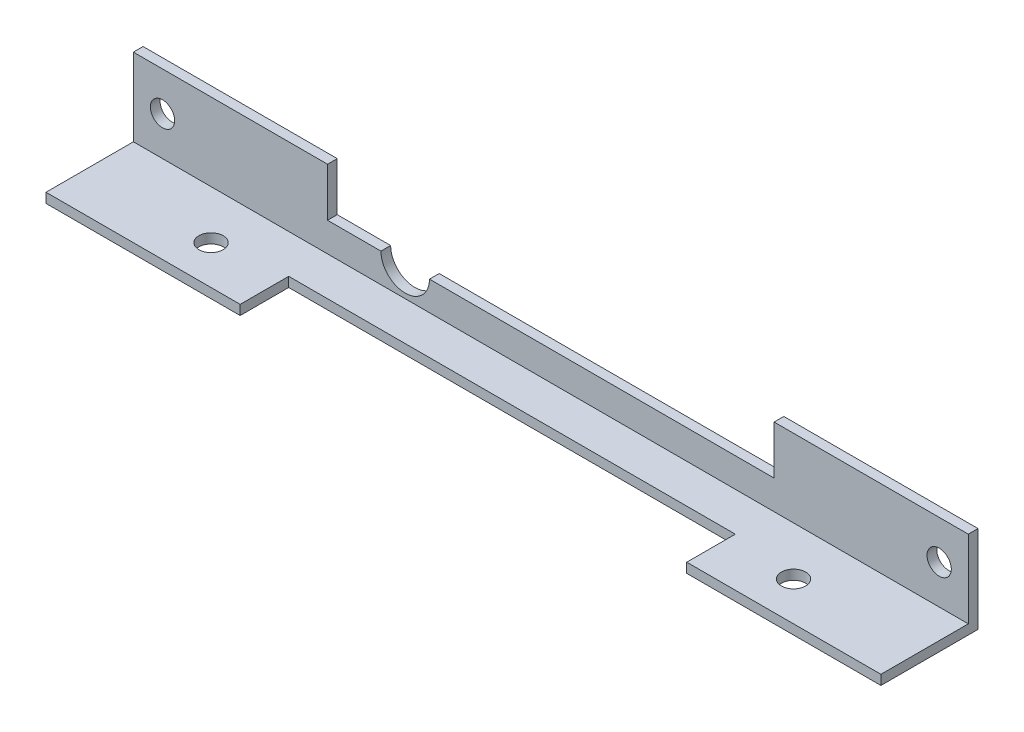
from build123d import *

# Parameters (mm, degrees)
ESQUISSE1_W             = 86
ESQUISSE1_H             = 10
BOSS_EXTRU_1_DEPTH      = 1
ESQUISSE2_W             = 86
ESQUISSE2_H             = 1
BOSS_EXTRU_2_DEPTH      = 8
ESQUISSE3_R             = 1.25
ENL_V_MAT_EXTRU_1_DEPTH = 10
ESQUISSE4_R             = 1.25
ENL_V_MAT_EXTRU_2_DEPTH = 10
ESQUISSE5_W             = 46
ESQUISSE5_H             = 5
ENL_V_MAT_EXTRU_3_DEPTH = 10
ESQUISSE6_W             = 46
ESQUISSE6_H             = 5
ENL_V_MAT_EXTRU_4_DEPTH = 10
ESQUISSE8_R             = 2.5
ENL_V_MAT_EXTRU_5_DEPTH = 10


with BuildPart() as part:
    # Esquisse1 → Boss.-Extru.1 (new body)
    with BuildSketch(Plane(origin=(0, 0, 0), x_dir=(1, 0, 0), z_dir=(0, 1, 0))):
        with Locations((-31.256880734, 5.871559633)):
            Rectangle(ESQUISSE1_W, ESQUISSE1_H)
    extrude(amount=BOSS_EXTRU_1_DEPTH)

    # Esquisse2 → Boss.-Extru.2 (add)
    with BuildSketch(Plane(origin=(0, 1, 0), x_dir=(1, 0, 0), z_dir=(0, 1, 0))):
        with Locations((-31.256880734, 10.371559633)):
            Rectangle(ESQUISSE2_W, ESQUISSE2_H)
    extrude(amount=BOSS_EXTRU_2_DEPTH)

    # Esquisse3 → Enlèv. mat.-Extru.1 (cut)
    with BuildSketch(Plane.XY.offset(-9.871559633)):
        with Locations((8.743119266, 5)):
            Circle(ESQUISSE3_R)
        with Locations((-71.256880734, 5)):
            Circle(ESQUISSE3_R)
    extrude(amount=-ENL_V_MAT_EXTRU_1_DEPTH, mode=Mode.SUBTRACT)

    # Esquisse4 → Enlèv. mat.-Extru.2 (cut)
    with BuildSketch(Plane(origin=(0, 1, 0), x_dir=(1, 0, 0), z_dir=(0, 1, 0))):
        with Locations(Location((-61.256880734, 4.871559633, 0), (0, 0, 270))):  # turned: the seam where the file's is
            Circle(ESQUISSE4_R)
        with Locations(Location((-1.256880734, 4.871559633, 0), (0, 0, 270))):  # turned: the seam where the file's is
            Circle(ESQUISSE4_R)
    extrude(amount=-ENL_V_MAT_EXTRU_2_DEPTH, mode=Mode.SUBTRACT)

    # Esquisse5 → Enlèv. mat.-Extru.3 (cut)
    with BuildSketch(Plane(origin=(0, 1, 0), x_dir=(1, 0, 0), z_dir=(0, 1, 0))):
        with Locations((-31.256880734, 3.371559633)):
            Rectangle(ESQUISSE5_W, ESQUISSE5_H)
    extrude(amount=-ENL_V_MAT_EXTRU_3_DEPTH, mode=Mode.SUBTRACT)

    # Esquisse6 → Enlèv. mat.-Extru.4 (cut)
    with BuildSketch(Plane.XY.offset(-9.871559633)):
        with Locations((-31.256880734, 6.5)):
            Rectangle(ESQUISSE6_W, ESQUISSE6_H)
    extrude(amount=-ENL_V_MAT_EXTRU_4_DEPTH, mode=Mode.SUBTRACT)

    # Esquisse8 → Enlèv. mat.-Extru.5 (cut)
    with BuildSketch(Plane.XY.offset(-9.871559633)):
        with Locations((-46.256880734, 4)):
            Circle(ESQUISSE8_R)
    extrude(amount=-ENL_V_MAT_EXTRU_5_DEPTH, mode=Mode.SUBTRACT)


solid = part.part
